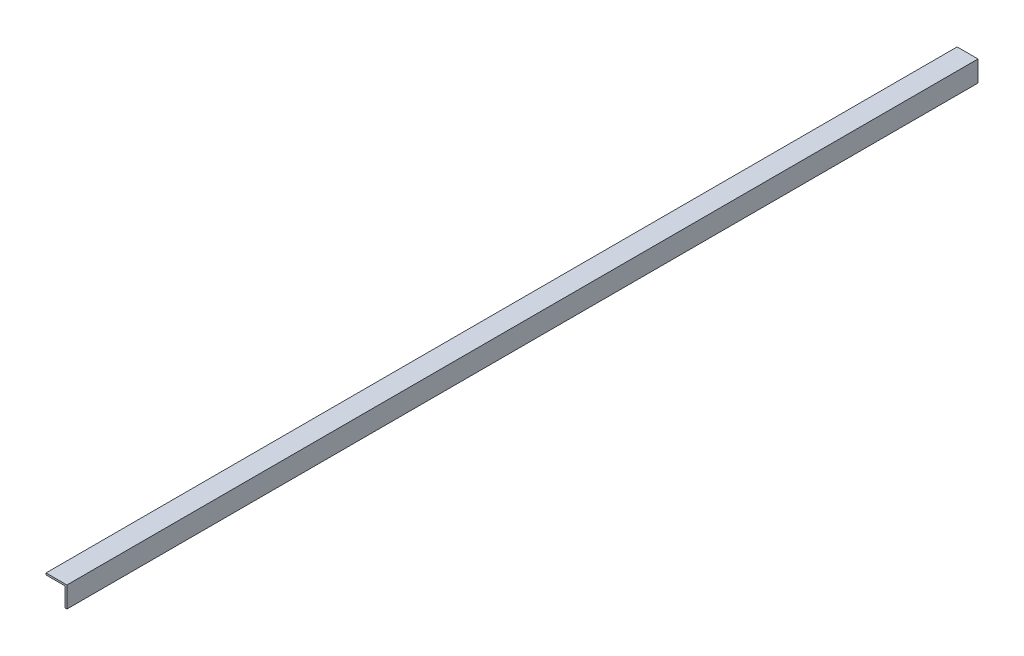
from build123d import *

# Parameters (mm, degrees)
BOSS_EXTRUDE1_DEPTH = 1662.1125


with BuildPart() as part:
    # Sketch1 → Boss-Extrude1 (new body)
    with BuildSketch(Plane.XY):
        Polygon((0, 0), (-38.1, 0), (-38.1, -3.175), (-3.175, -3.175), (-3.175, -38.1), (0, -38.1), align=None)
    extrude(amount=BOSS_EXTRUDE1_DEPTH)


solid = part.part
